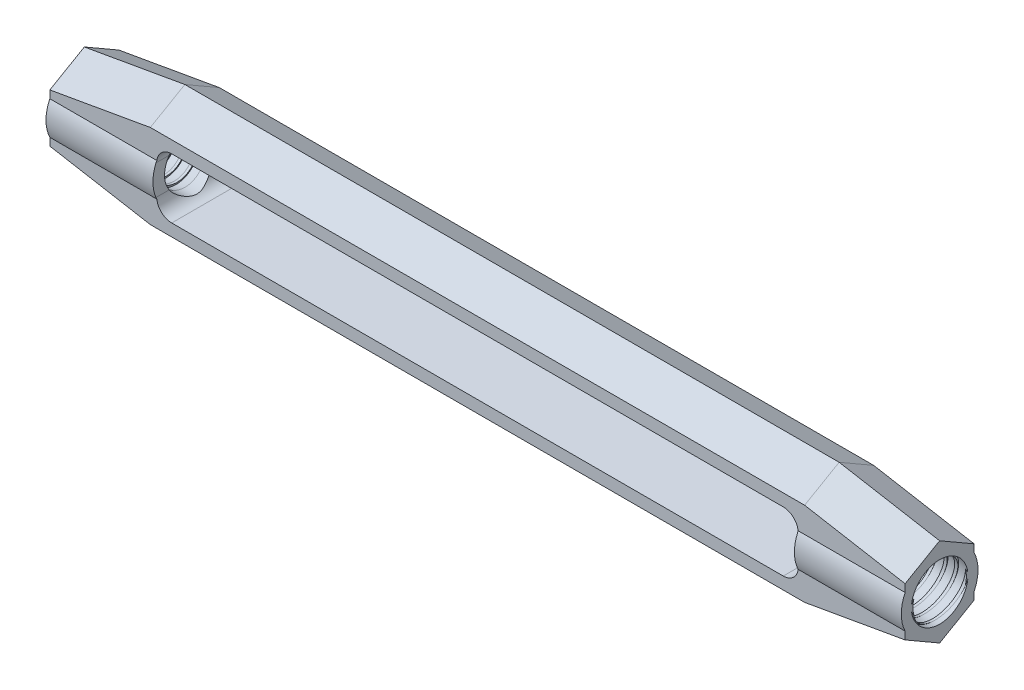
from build123d import *

# Parameters (mm, degrees)
EXTRUDE1_DEPTH          = 50.8
CUT_EXTRUDE3_DEPTH      = 51.8
CUT_EXTRUDE4_DEPTH      = 50.8
MIRROR4_COPY_1_DEPTH    = 50.8
MIRROR4_COPY_2_DEPTH    = 50.8
SKETCH2_W               = 76.2
SKETCH2_H               = 7.112
CUT_EXTRUDE1_DEPTH      = 5.556125
CUT_EXTRUDE1_DEPTH_BACK = 5.556125
FILLET1_R               = 1.778
SKETCH13_W              = 101.6
SKETCH13_H              = 3.175
LPATTERN1_COUNT         = 10
LPATTERN1_PITCH         = 1.27


with BuildPart() as part:
    # Sketch1 → Extrude1 (new body, symmetric)
    with BuildSketch(Plane(origin=(0, 0, 0), x_dir=(0, 0, -1), z_dir=(1, 0, 0))):
        Polygon((0, -7.366), (5.207, -4.359737148), (5.207, 4.359737148), (0, 7.366), (-5.207, 4.359737148), (-5.207, -4.359737148), align=None)
    extrude(amount=EXTRUDE1_DEPTH, both=True)

    # Sketch23 → Cut-Extrude3 (cut, symmetric)
    with BuildSketch(Plane(origin=(0, 0, 0), x_dir=(0, 0, -1), z_dir=(1, 0, 0))):
        with BuildLine():
            Line((-4.1005125, 7.366), (-4.1005125, 1.985968845))
            ThreePointArc((-4.1005125, 1.985968845), (-4.556125, 0), (-4.1005125, -1.985968845))
            Line((-4.1005125, -1.985968845), (-4.1005125, -7.366))
            Line((-4.1005125, -7.366), (-5.207, -7.366))
            Line((-5.207, -7.366), (-5.207, 7.366))
            Line((-5.207, 7.366), (-4.1005125, 7.366))
        make_face()
    cut_extrude3 = extrude(amount=CUT_EXTRUDE3_DEPTH, both=True, mode=Mode.SUBTRACT)

    # Mirror2: Cut-Extrude3 across plane
    add(cut_extrude3.mirror(Plane.XY), mode=Mode.SUBTRACT)

    # Sketch24 → Cut-Extrude4 (cut, along a direction that is not the sketch's normal)
    with BuildSketch(Plane(origin=(50.8, 0, 0), x_dir=(0, 0, -1), z_dir=(1, 0, 0))):
        Polygon((-5.207, 2.254697139), (0, 5.26095999), (5.207, 2.254697139), (5.207, 7.366), (-5.207, 7.366), align=None)
    cut_extrude4 = extrude(amount=-CUT_EXTRUDE4_DEPTH, dir=(0.984807753, -0.173648178, 0), mode=Mode.SUBTRACT)

    # Mirror3: Cut-Extrude4 across plane
    add(cut_extrude4.mirror(Plane.ZX), mode=Mode.SUBTRACT)

    # Mirror4 copy 1 sketch → Mirror4 copy 1 (cut, along a direction that is not the sketch's normal)
    with BuildSketch(Plane(origin=(-50.8, 0, 0), x_dir=(0, 0, -1), z_dir=(-1, 0, 0))):
        Polygon((-5.207, 2.254697139), (0, 5.26095999), (5.207, 2.254697139), (5.207, 7.366), (-5.207, 7.366), align=None)
    extrude(amount=-MIRROR4_COPY_1_DEPTH, dir=(-0.984807753, 0.173648178, 0), mode=Mode.SUBTRACT)

    # Mirror4 copy 2 sketch → Mirror4 copy 2 (cut, along a direction that is not the sketch's normal)
    with BuildSketch(Plane(origin=(-50.8, 0, 0), x_dir=(0, 0, -1), z_dir=(-1, 0, 0))):
        Polygon((-5.207, -2.254697139), (0, -5.26095999), (5.207, -2.254697139), (5.207, -7.366), (-5.207, -7.366), align=None)
    extrude(amount=-MIRROR4_COPY_2_DEPTH, dir=(-0.984807753, -0.173648178, 0), mode=Mode.SUBTRACT)

    # Sketch2 → Cut-Extrude1 (cut, two sides)
    with BuildSketch(Plane.XY) as cut_extrude1_sk:
        Rectangle(SKETCH2_W, SKETCH2_H)
    extrude(amount=CUT_EXTRUDE1_DEPTH, mode=Mode.SUBTRACT)
    extrude(cut_extrude1_sk.sketch, amount=-CUT_EXTRUDE1_DEPTH_BACK, mode=Mode.SUBTRACT)

    # Fillet1
    fillet1_edges = [part.edges().sort_by_distance(p)[0] for p in [
        (38.1, 3.556, 0),
        (38.1, -3.556, 0),
        (-38.1, -3.556, 0),
        (-38.1, 3.556, 0),
    ]]
    fillet(fillet1_edges, radius=FILLET1_R)

    # Sketch13 → Cut-Revolve7 (revolve, cut)
    with BuildSketch(Plane.XY):
        with Locations((0, 1.5875)):
            Rectangle(SKETCH13_W, SKETCH13_H)
    revolve(axis=Axis((-411.1625, 0, 0), (1, 0, 0)), mode=Mode.SUBTRACT)

    # Sketch22 → Cut-Revolve8 (revolve, cut)
    with BuildSketch(Plane.XY):
        Polygon((52.642855231, 3.206133436), (51.553184955, 3.424067492), (51.807541176, 2.672175229), (52.118875541, 2.609908356), align=None)
    cut_revolve8 = revolve(axis=Axis((50.73449768, 0.140100464, 0), (0.980580676, -0.196116135, 0)), mode=Mode.SUBTRACT)

    # LPattern1: Cut-Revolve8 ×10
    with Locations(*[(-i * LPATTERN1_PITCH, 0, 0) for i in range(1, LPATTERN1_COUNT)]):
        add(cut_revolve8, mode=Mode.SUBTRACT)

    # Mirror1: Cut-Revolve8 across plane
    add(cut_revolve8.mirror(Plane(origin=(0, 0, 0), x_dir=(0, 0, 1), z_dir=(1, 0, 0))), mode=Mode.SUBTRACT)

    # Mirror1 copy 1 sketch → Mirror1 copy 1 (revolve, cut)
    with BuildSketch(Plane(origin=(1.27, 0, 0), x_dir=(-1, 0, 0), z_dir=(0, 0, 1))):
        Polygon((52.642855231, -3.206133436), (51.553184955, -3.424067492), (51.807541176, -2.672175229), (52.118875541, -2.609908356), align=None)
    revolve(axis=Axis((-49.46449768, 0.140100464, 0), (0.980580676, 0.196116135, 0)), mode=Mode.SUBTRACT)

    # Mirror1 copy 2 sketch → Mirror1 copy 2 (revolve, cut)
    with BuildSketch(Plane(origin=(2.54, 0, 0), x_dir=(-1, 0, 0), z_dir=(0, 0, 1))):
        Polygon((52.642855231, -3.206133436), (51.553184955, -3.424067492), (51.807541176, -2.672175229), (52.118875541, -2.609908356), align=None)
    revolve(axis=Axis((-48.19449768, 0.140100464, 0), (0.980580676, 0.196116135, 0)), mode=Mode.SUBTRACT)

    # Mirror1 copy 3 sketch → Mirror1 copy 3 (revolve, cut)
    with BuildSketch(Plane(origin=(3.81, 0, 0), x_dir=(-1, 0, 0), z_dir=(0, 0, 1))):
        Polygon((52.642855231, -3.206133436), (51.553184955, -3.424067492), (51.807541176, -2.672175229), (52.118875541, -2.609908356), align=None)
    revolve(axis=Axis((-46.92449768, 0.140100464, 0), (0.980580676, 0.196116135, 0)), mode=Mode.SUBTRACT)

    # Mirror1 copy 4 sketch → Mirror1 copy 4 (revolve, cut)
    with BuildSketch(Plane(origin=(5.08, 0, 0), x_dir=(-1, 0, 0), z_dir=(0, 0, 1))):
        Polygon((52.642855231, -3.206133436), (51.553184955, -3.424067492), (51.807541176, -2.672175229), (52.118875541, -2.609908356), align=None)
    revolve(axis=Axis((-45.65449768, 0.140100464, 0), (0.980580676, 0.196116135, 0)), mode=Mode.SUBTRACT)

    # Mirror1 copy 5 sketch → Mirror1 copy 5 (revolve, cut)
    with BuildSketch(Plane(origin=(6.35, 0, 0), x_dir=(-1, 0, 0), z_dir=(0, 0, 1))):
        Polygon((52.642855231, -3.206133436), (51.553184955, -3.424067492), (51.807541176, -2.672175229), (52.118875541, -2.609908356), align=None)
    revolve(axis=Axis((-44.38449768, 0.140100464, 0), (0.980580676, 0.196116135, 0)), mode=Mode.SUBTRACT)

    # Mirror1 copy 6 sketch → Mirror1 copy 6 (revolve, cut)
    with BuildSketch(Plane(origin=(7.62, 0, 0), x_dir=(-1, 0, 0), z_dir=(0, 0, 1))):
        Polygon((52.642855231, -3.206133436), (51.553184955, -3.424067492), (51.807541176, -2.672175229), (52.118875541, -2.609908356), align=None)
    revolve(axis=Axis((-43.11449768, 0.140100464, 0), (0.980580676, 0.196116135, 0)), mode=Mode.SUBTRACT)

    # Mirror1 copy 7 sketch → Mirror1 copy 7 (revolve, cut)
    with BuildSketch(Plane(origin=(8.89, 0, 0), x_dir=(-1, 0, 0), z_dir=(0, 0, 1))):
        Polygon((52.642855231, -3.206133436), (51.553184955, -3.424067492), (51.807541176, -2.672175229), (52.118875541, -2.609908356), align=None)
    revolve(axis=Axis((-41.84449768, 0.140100464, 0), (0.980580676, 0.196116135, 0)), mode=Mode.SUBTRACT)

    # Mirror1 copy 8 sketch → Mirror1 copy 8 (revolve, cut)
    with BuildSketch(Plane(origin=(10.16, 0, 0), x_dir=(-1, 0, 0), z_dir=(0, 0, 1))):
        Polygon((52.642855231, -3.206133436), (51.553184955, -3.424067492), (51.807541176, -2.672175229), (52.118875541, -2.609908356), align=None)
    revolve(axis=Axis((-40.57449768, 0.140100464, 0), (0.980580676, 0.196116135, 0)), mode=Mode.SUBTRACT)

    # Mirror1 copy 9 sketch → Mirror1 copy 9 (revolve, cut)
    with BuildSketch(Plane(origin=(11.43, 0, 0), x_dir=(-1, 0, 0), z_dir=(0, 0, 1))):
        Polygon((52.642855231, -3.206133436), (51.553184955, -3.424067492), (51.807541176, -2.672175229), (52.118875541, -2.609908356), align=None)
    revolve(axis=Axis((-39.30449768, 0.140100464, 0), (0.980580676, 0.196116135, 0)), mode=Mode.SUBTRACT)


solid = part.part
